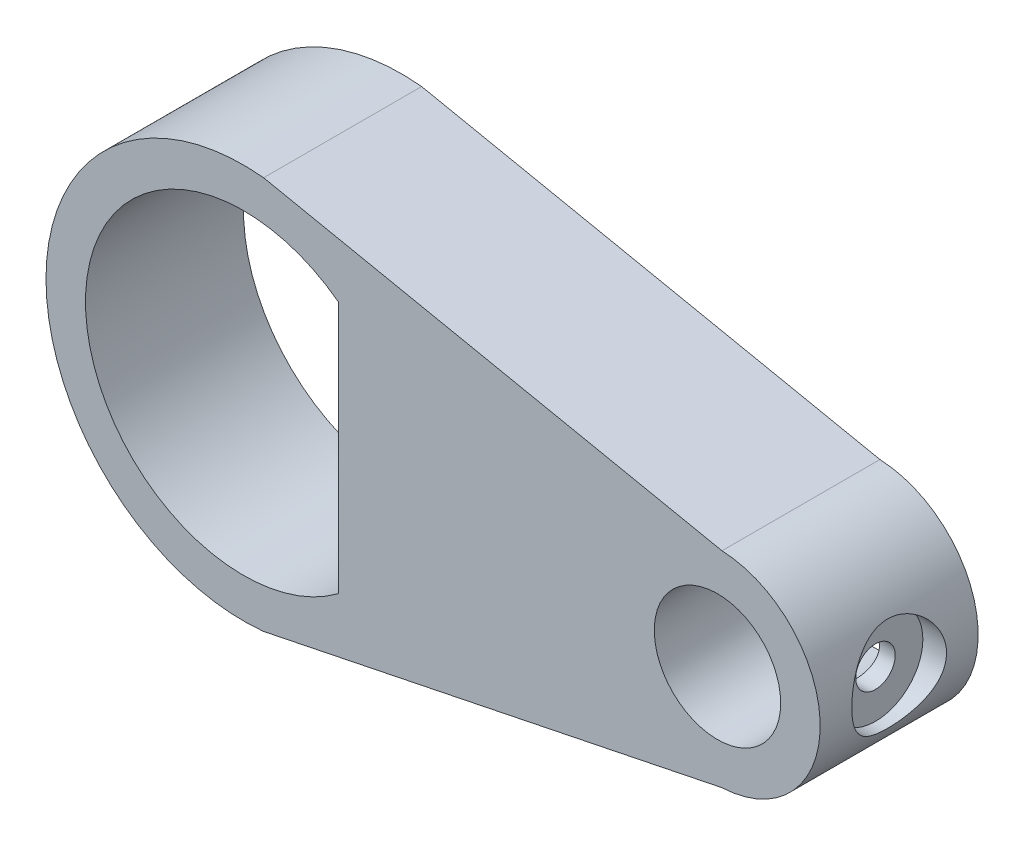
from build123d import *

# Parameters (mm, degrees)
SKETCH1_R           = 4
BOSS_EXTRUDE1_DEPTH = 10
CUT_EXTRUDE1_DEPTH  = 7
SKETCH3_R           = 3
CUT_EXTRUDE2_DEPTH  = 2


with BuildPart() as part:
    # Sketch1 → Boss-Extrude1 (new body)
    with BuildSketch(Plane.XY):
        with BuildLine():
            Line((15.283584765, 6.493810875), (-13.726969973, 12.435006817))
            ThreePointArc((-13.726969973, 12.435006817), (-27.5, 0), (-13.726969973, -12.435006817))
            Line((-13.726969973, -12.435006817), (15.283584765, -6.493810875))
            ThreePointArc((15.283584765, -6.493810875), (21.5, 0), (15.283584765, 6.493810875))
        make_face()
        with Locations((15, 0)):
            Circle(SKETCH1_R, mode=Mode.SUBTRACT)
        with BuildLine():
            Line((-9, -8), (-9, 8))
            ThreePointArc((-9, 8), (-25, 0), (-9, -8))
        make_face(mode=Mode.SUBTRACT)
    extrude(amount=BOSS_EXTRUDE1_DEPTH)

    # Sketch2 → Cut-Extrude1 (cut)
    with BuildSketch(Plane(origin=(22, 0, 0), x_dir=(0, 0, -1), z_dir=(1, 0, 0))):
        with BuildLine():
            ThreePointArc((-6.25, 0), (-5, -1.25), (-3.75, 0))
            Line((-3.75, 0), (-6.25, 0))
        make_face()
        with BuildLine():
            Line((-6.25, 0), (-3.75, 0))
            ThreePointArc((-3.75, 0), (-5, 1.25), (-6.25, 0))
        make_face()
    extrude(amount=-CUT_EXTRUDE1_DEPTH, mode=Mode.SUBTRACT)

    # Sketch3 → Cut-Extrude2 (cut)
    with BuildSketch(Plane(origin=(22, 0, 0), x_dir=(0, 0, -1), z_dir=(1, 0, 0))):
        with Locations((-5, 0)):
            Circle(SKETCH3_R)
    extrude(amount=-CUT_EXTRUDE2_DEPTH, mode=Mode.SUBTRACT)


solid = part.part
